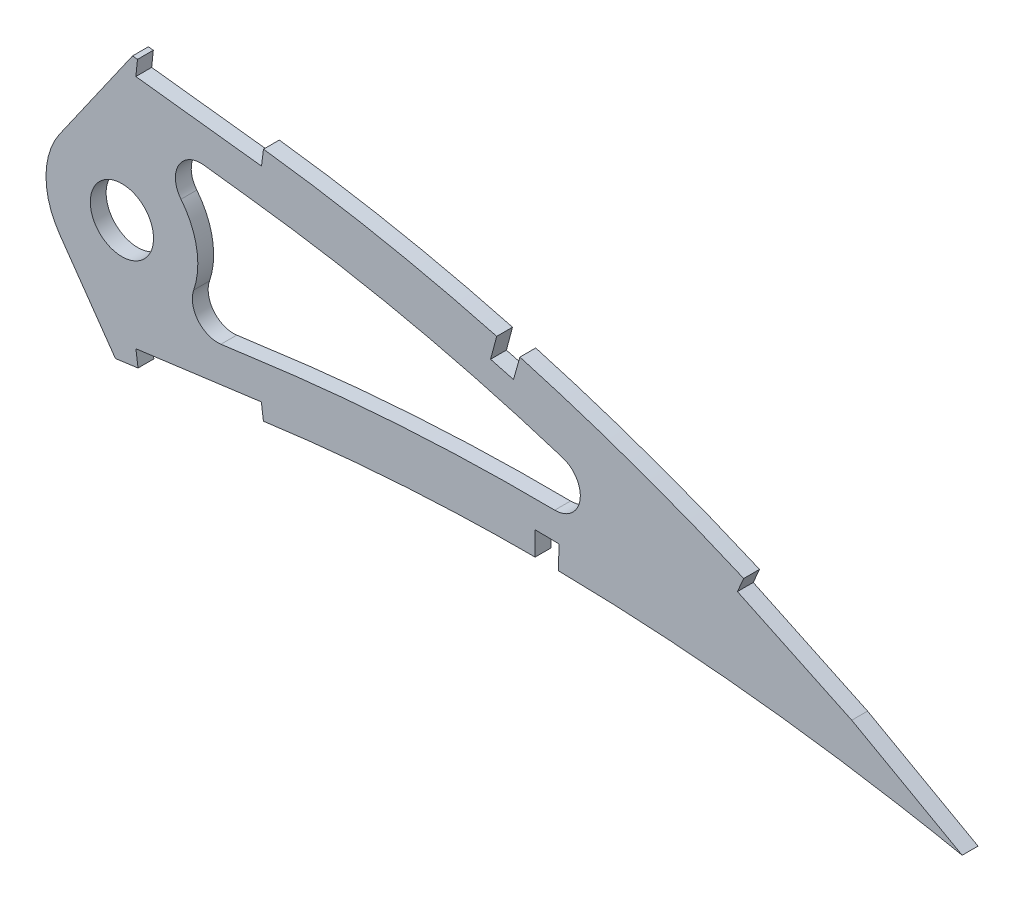
from build123d import *

# Parameters (mm, degrees)
BOSS_EXTRUDE1_DEPTH = 3.175
SKETCH3_R           = 6.35
CUT_EXTRUDE2_DEPTH  = 7.62
CUT_EXTRUDE3_DEPTH  = 4.1750001
FILLET1_R           = 5.08


with BuildPart() as part:
    # Sketch1 → Boss-Extrude1 (new body)
    with BuildSketch(Plane.XY):
        with BuildLine():
            Line((485.587399664, -0.75798934), (490.147728055, -1.684578565))
            Line((490.147728055, -1.684578565), (486.193791136, 0.75798934))
            add(Edge.make_bspline(
                [(486.193791136, 0.75798934), (486.156545565, 0.780998011), (486.007707871, 0.872943377), (485.672349582, 1.078647636), (485.113908292, 1.42125844), (484.332139179, 1.898395939), (483.327649378, 2.508793191), (482.099933618, 3.248176053), (480.649758178, 4.11414228), (478.977474042, 5.102596174), (477.083252712, 6.208909725), (474.9678154, 7.428600903), (472.631346146, 8.754764469), (470.074750091, 10.181981707), (467.298904376, 11.703464898), (464.304334104, 13.312342155), (461.092111509, 15.00042968), (457.663469746, 16.760467008), (454.019033833, 18.582734695), (450.160522056, 20.459648763), (446.08922006, 22.381851369), (441.806517314, 24.339086509), (437.314874314, 26.32337623), (432.615532729, 28.322383702), (427.711170694, 30.327448406), (422.603876177, 32.32715893), (417.296673201, 34.312408193), (411.791609239, 36.270335128), (406.092799427, 38.19238362), (400.203008281, 40.066067188), (394.126447785, 41.881210299), (387.866648542, 43.626044211), (381.42882875, 45.291620487), (374.81707141, 46.865809768), (368.036980395, 48.338075006), (361.093945075, 49.699552264), (353.993788332, 50.936649002), (346.7561854, 52.048400815), (339.497587697, 52.97319004), (332.253923966, 53.880196397), (325.021047815, 54.732245847), (317.699770737, 55.548201081), (310.297136308, 56.323468086), (302.820487344, 57.055622539), (295.277392798, 57.741504683), (287.675691417, 58.379102964), (280.022738792, 58.964804598), (272.326604726, 59.497707184), (264.594897726, 59.973125915), (256.835853078, 60.39070372), (249.05734719, 60.747528421), (241.267474913, 61.041141246), (233.474507978, 61.269769861), (225.686535745, 61.431223873), (217.911990598, 61.524488163), (210.158959277, 61.547014441), (202.435870244, 61.498399603), (194.750810842, 61.376974546), (187.112218127, 61.181076903), (179.528190462, 60.910341158), (172.006928802, 60.56488465), (164.556668167, 60.141814477), (157.185490761, 59.643826715), (149.90160498, 59.068829465), (142.713013757, 58.416669795), (135.627250794, 57.690066178), (128.652204991, 56.887042275), (121.795351463, 56.009883049), (115.064190238, 55.060308222), (108.466273869, 54.03780049), (102.008670179, 52.945313451), (95.69834878, 51.783964779), (89.541985966, 50.557159213), (83.546284377, 49.265216856), (77.717590812, 47.912013041), (72.061962755, 46.499905586), (66.585479912, 45.031479446), (61.293693841, 43.510258272), (56.191955701, 41.93969324), (51.286212878, 40.321510147), (46.580173058, 38.661844322), (42.079617138, 36.961873954), (37.787992638, 35.226836263), (33.71032906, 33.459100147), (29.849672544, 31.664054679), (26.210392495, 29.843743399), (22.795082621, 28.003266258), (19.607171667, 26.145445317), (16.649728276, 24.273731457), (13.923995526, 22.392872215), (11.433731376, 20.504048278), (9.179791317, 18.61203256), (7.163601692, 16.719706143), (5.388044474, 14.828372521), (3.853055719, 12.941362387), (2.560647106, 11.060170164), (1.511042845, 9.186575935), (0.706617001, 7.321940679), (0.14657185, 5.467313049), (-0.159993132, 3.625430402), (-0.236298987, 1.794816138), (-0.078648638, 0.597378122), (0, 0)],
                knots=[0, 0, 0, 0, 0.00025409, 0.001015373, 0.002283359, 0.004056577, 0.006330982, 0.009105274, 0.012374489, 0.016134023, 0.020379661, 0.025105976, 0.030306237, 0.035972206, 0.042099522, 0.048678064, 0.055701664, 0.063160184, 0.071045824, 0.079349827, 0.08806291, 0.097175757, 0.106678111, 0.116561573, 0.126814276, 0.137428301, 0.148393618, 0.15969976, 0.171338125, 0.183297699, 0.195569604, 0.208143556, 0.221011593, 0.234161831, 0.24758745, 0.261276822, 0.27522271, 0.289414144, 0.3037712, 0.317689226, 0.331784111, 0.346039677, 0.36044387, 0.374982721, 0.389640454, 0.404403317, 0.4192566, 0.434186749, 0.449177265, 0.464214782, 0.479284009, 0.49436974, 0.509457833, 0.524532346, 0.53957932, 0.554582984, 0.569529546, 0.584403417, 0.599190992, 0.613876838, 0.628447475, 0.642888675, 0.657186054, 0.671325546, 0.685294014, 0.699078147, 0.712665095, 0.726042645, 0.739197713, 0.752117586, 0.764792042, 0.777208152, 0.789355685, 0.80122396, 0.812803686, 0.824082909, 0.835054602, 0.845709571, 0.856037853, 0.866033834, 0.875688843, 0.884997719, 0.893953426, 0.902552897, 0.910789386, 0.918660734, 0.926166253, 0.933302626, 0.94007122, 0.94647478, 0.952517526, 0.958204819, 0.963546652, 0.9685566, 0.973249913, 0.977651041, 0.981787043, 0.985694226, 0.989415109, 0.993001157, 0.996508416, 1, 1, 1, 1], degree=3))
            add(Edge.make_bspline(
                [(0, 0), (0.124852845, -0.589388692), (0.375132337, -1.770874799), (1.055109044, -3.471725282), (1.954345773, -5.106735278), (3.091715472, -6.671561797), (4.459655687, -8.165777182), (6.055145152, -9.59093561), (7.876619233, -10.946270738), (9.92169391, -12.231165798), (12.187398396, -13.446984767), (14.671186068, -14.592971696), (17.370792198, -15.668768481), (20.283275494, -16.672937055), (23.405075375, -17.607006726), (26.733223776, -18.468701274), (30.263936284, -19.259225009), (33.993816996, -19.976560109), (37.918801514, -20.621435301), (42.034812323, -21.193489669), (46.337624631, -21.693081077), (50.82301706, -22.119161118), (55.4865531, -22.47264634), (60.323584549, -22.753771214), (65.329416188, -22.963427152), (70.499252954, -23.100817142), (75.828031579, -23.168083162), (81.310936338, -23.16623498), (86.942603653, -23.09477832), (92.718222737, -22.957660649), (98.632251256, -22.754013473), (104.679350026, -22.486301136), (110.854064483, -22.157217858), (117.150856575, -21.767879174), (123.564184912, -21.320010643), (130.088480981, -20.817203984), (136.717818035, -20.260713235), (143.446414433, -19.653782206), (150.268313286, -18.999449162), (157.177620607, -18.29978506), (164.168237687, -17.558081099), (171.233938121, -16.77674083), (178.368711149, -15.959932594), (185.566039209, -15.10913432), (192.819836156, -14.229203613), (200.123278023, -13.321821748), (207.470257634, -12.390483576), (214.854167095, -11.43957439), (222.268093801, -10.46898568), (229.705802131, -9.485632582), (237.16011938, -8.488705064), (244.624557097, -7.483330472), (252.092205531, -6.472633763), (259.555791095, -5.456925983), (267.00875308, -4.440416464), (274.444177456, -3.425895825), (281.854781181, -2.413456633), (289.233859631, -1.408131206), (296.573982386, -0.40979664), (303.868380953, 0.579523), (311.110065241, 1.55687475), (318.292203182, 2.521024953), (325.407385919, 3.471363717), (332.448454941, 4.408247897), (339.302915498, 5.303240759), (345.952856872, 6.204000824), (352.420688138, 6.942424504), (358.80798662, 7.572695641), (365.121387221, 8.089431053), (371.353308903, 8.500064921), (377.496611311, 8.807531395), (383.543972889, 9.016123146), (389.487754946, 9.132028332), (395.320533551, 9.158188245), (401.034347101, 9.102945563), (406.621764277, 8.970753247), (412.074986888, 8.767544827), (417.386407281, 8.500176147), (422.548480993, 8.175935919), (427.553458197, 7.799606866), (432.394364707, 7.379974648), (437.06373176, 6.923182232), (441.554389355, 6.434448486), (445.859785012, 5.92401425), (449.973027478, 5.395240442), (453.887929886, 4.85681652), (457.598190253, 4.314198878), (461.097932514, 3.774315295), (464.381658048, 3.242315892), (467.444062607, 2.72526199), (470.280349076, 2.227984348), (472.885595604, 1.755339323), (475.25618804, 1.313290259), (477.38744454, 0.904033197), (479.2765147, 0.534312721), (480.919885909, 0.205760173), (482.315149055, -0.076995438), (483.459867496, -0.312838295), (484.352302675, -0.497896754), (484.990691913, -0.632466588), (485.3743447, -0.712542465), (485.54480657, -0.748903783), (485.587399664, -0.75798934)],
                knots=[0, 0, 0, 0, 0.003638255, 0.007293231, 0.011028136, 0.014901081, 0.018963272, 0.023258475, 0.027820626, 0.032679082, 0.03785316, 0.043361875, 0.049214679, 0.055422346, 0.061988786, 0.068918036, 0.076211157, 0.083868392, 0.091887411, 0.100265912, 0.108999867, 0.118084529, 0.127514843, 0.13728527, 0.147387917, 0.157816481, 0.168563473, 0.179619128, 0.190977373, 0.202626974, 0.214560478, 0.226767249, 0.239236417, 0.251959004, 0.264923894, 0.278119703, 0.291536035, 0.30516028, 0.318980685, 0.332985499, 0.34716279, 0.361498603, 0.375980747, 0.390597192, 0.405332593, 0.420174823, 0.435109533, 0.450124276, 0.465203068, 0.480333154, 0.495500583, 0.510689775, 0.525887334, 0.541078314, 0.556247233, 0.571381785, 0.58646604, 0.601484516, 0.616424329, 0.631269423, 0.646006524, 0.660620684, 0.675098188, 0.689422858, 0.703581824, 0.716907564, 0.730009274, 0.742952128, 0.755725558, 0.768319952, 0.780724337, 0.792926528, 0.804916041, 0.816679084, 0.828203524, 0.8394749, 0.850481359, 0.861207697, 0.871639326, 0.881763414, 0.891563605, 0.901027364, 0.910138977, 0.918883976, 0.927249278, 0.935221104, 0.942784738, 0.949928188, 0.956638464, 0.962904204, 0.968712288, 0.974054485, 0.978918432, 0.983297218, 0.987180246, 0.990560674, 0.993433357, 0.995790626, 0.997629587, 0.998945816, 0.999736592, 1, 1, 1, 1], degree=3))
        make_face()
    extrude(amount=BOSS_EXTRUDE1_DEPTH)

    # Sketch3 → Cut-Extrude2 (cut)
    with BuildSketch(Plane(origin=(0, 0, 0), x_dir=(-1, 0, 0), z_dir=(0, 0, -1))):
        with Locations((-312.347728055, 26.255421435)):
            Circle(SKETCH3_R)
    extrude(amount=-CUT_EXTRUDE2_DEPTH, mode=Mode.SUBTRACT)

    # Sketch4 → Cut-Extrude3 (cut, through all)
    with BuildSketch(Plane.XY.offset(3.175)):
        with BuildLine():
            ThreePointArc((328.764508398, 44.057939686), (323.718114066, 41.472789893), (324.209352335, 35.824092683))
            ThreePointArc((324.209352335, 35.824092683), (326.71833615, 31.329199415), (327.587728055, 26.255421435))
            ThreePointArc((327.587728055, 26.255421435), (325.504689508, 18.564389947), (319.825002945, 12.975814504))
            add(Edge.make_bspline(
                [(319.825002945, 12.975814504), (322.942820543, 13.392982967), (327.669877473, 14.024410231), (334.043339236, 14.862306396), (338.826488009, 15.492744251), (343.715664565, 16.151243809), (350.398623717, 16.952918213), (358.659540226, 17.783012705), (371.975290063, 18.792080277), (388.632726581, 19.430303401), (408.634763224, 19.217007594), (423.010853589, 18.377885686), (430.71684566, 17.722490027), (431.790737707, 17.62717887)],
                knots=[0.666430442, 0.666430442, 0.666430442, 0.666430442, 0.68544632, 0.695276122, 0.705105925, 0.714935727, 0.72476553, 0.744425135, 0.76408474, 0.80340395, 0.84272316, 0.88204237, 0.888412077, 0.888412077, 0.888412077, 0.888412077], degree=3))
            add(Edge.make_bspline(
                [(431.790737707, 17.62717887), (424.191477956, 20.8804212), (410.26123131, 26.282114189), (389.664440925, 32.773092285), (373.49731798, 36.840967689), (360.45479955, 39.506645362), (350.575577074, 41.228299699), (342.418796355, 42.368826827), (335.861477143, 43.188937517), (332.31248965, 43.629530132), (330.029806008, 43.906550774), (329.186314467, 44.00766024), (328.764508398, 44.057939686)],
                knots=[0.110005658, 0.110005658, 0.110005658, 0.110005658, 0.159341904, 0.19917738, 0.239012856, 0.258930594, 0.278848332, 0.298766071, 0.30872494, 0.317222758, 0.319712475, 0.322202192, 0.322202192, 0.322202192, 0.322202192], degree=3))
        make_face()
        with BuildLine():
            add(Edge.make_bspline(
                [(340.771051926, 52.809255955), (340.321486075, 52.866397518), (337.492730725, 53.224225716), (332.253923966, 53.880196397), (325.021047815, 54.732245847), (319.418146413, 55.356688369), (316.22734967, 55.698361537), (315.478729578, 55.7777567)],
                knots=[0.301141045, 0.301141045, 0.301141045, 0.301141045, 0.3037712, 0.317689226, 0.331784111, 0.346039677, 0.350408935, 0.350408935, 0.350408935, 0.350408935], degree=3))
            Line((315.478729578, 55.7777567), (315.143881725, 52.620463253))
            Line((315.143881725, 52.620463253), (340.370717936, 49.659596022))
            Line((340.370717936, 49.659596022), (340.771051926, 52.809255955))
        make_face()
        with BuildLine():
            ThreePointArc((299.8638509, 17.514116545), (297.107728055, 26.255421435), (299.8638509, 34.996726325))
            Line((299.8638509, 34.996726325), (307.815975435, 46.353537128))
            Line((307.815975435, 46.353537128), (314.488133694, 55.882366646))
            add(Edge.make_bspline(
                [(314.488133694, 55.882366646), (313.098819132, 56.028454072), (309.217441166, 56.429197753), (302.820487344, 57.055622539), (295.277392798, 57.741504683), (287.675691417, 58.379102964), (280.022738792, 58.964804598), (272.326604726, 59.497707184), (264.594897726, 59.973125915), (256.835853078, 60.39070372), (249.05734719, 60.747528421), (241.267474913, 61.041141246), (233.474507978, 61.269769861), (225.686535745, 61.431223873), (217.911990598, 61.524488163), (210.158959277, 61.547014441), (202.435870244, 61.498399603), (194.750810842, 61.376974546), (187.112218127, 61.181076903), (179.528190462, 60.910341158), (172.957215359, 60.608531938), (168.9157909, 60.387388325), (167.381438987, 60.29830405)],
                knots=[0.35233602, 0.35233602, 0.35233602, 0.35233602, 0.36044387, 0.374982721, 0.389640454, 0.404403317, 0.4192566, 0.434186749, 0.449177265, 0.464214782, 0.479284009, 0.49436974, 0.509457833, 0.524532346, 0.53957932, 0.554582984, 0.569529546, 0.584403417, 0.599190992, 0.613876838, 0.628447475, 0.637367617, 0.637367617, 0.637367617, 0.637367617], degree=3))
            add(Edge.make_bspline(
                [(167.381438987, 60.29830405), (166.431762902, 60.243165979), (163.023204812, 60.038215562), (157.185490761, 59.643826715), (149.90160498, 59.068829465), (142.713013757, 58.416669795), (135.627250794, 57.690066178), (128.652204991, 56.887042275), (121.795351463, 56.009883049), (115.064190238, 55.060308222), (108.466273869, 54.03780049), (102.008670179, 52.945313451), (95.69834878, 51.783964779), (89.541985966, 50.557159213), (83.546284377, 49.265216856), (77.717590812, 47.912013041), (72.061962755, 46.499905586), (66.585479912, 45.031479446), (61.293693841, 43.510258272), (56.191955701, 41.93969324), (51.286212878, 40.321510147), (46.580173058, 38.661844322), (42.079617138, 36.961873954), (37.787992638, 35.226836263), (33.71032906, 33.459100147), (29.849672544, 31.664054679), (26.210392495, 29.843743399), (22.795082621, 28.003266258), (19.607171667, 26.145445317), (16.649728276, 24.273731457), (13.923995526, 22.392872215), (11.433731376, 20.504048278), (9.179791317, 18.61203256), (7.163601692, 16.719706143), (5.388044474, 14.828372521), (3.853055719, 12.941362387), (2.560647106, 11.060170164), (1.511042845, 9.186575935), (0.706617001, 7.321940679), (0.14657185, 5.467313049), (-0.159993132, 3.625430402), (-0.236298987, 1.794816138), (-0.078648638, 0.597378122), (0, 0)],
                knots=[0.637367617, 0.637367617, 0.637367617, 0.637367617, 0.642888675, 0.657186054, 0.671325546, 0.685294014, 0.699078147, 0.712665095, 0.726042645, 0.739197713, 0.752117586, 0.764792042, 0.777208152, 0.789355685, 0.80122396, 0.812803686, 0.824082909, 0.835054602, 0.845709571, 0.856037853, 0.866033834, 0.875688843, 0.884997719, 0.893953426, 0.902552897, 0.910789386, 0.918660734, 0.926166253, 0.933302626, 0.94007122, 0.94647478, 0.952517526, 0.958204819, 0.963546652, 0.9685566, 0.973249913, 0.977651041, 0.981787043, 0.985694226, 0.989415109, 0.993001157, 0.996508416, 1, 1, 1, 1], degree=3))
            add(Edge.make_bspline(
                [(0, 0), (0.124852845, -0.589388692), (0.375132337, -1.770874799), (1.055109044, -3.471725282), (1.954345773, -5.106735278), (3.091715472, -6.671561797), (4.459655687, -8.165777182), (6.055145152, -9.59093561), (7.876619233, -10.946270738), (9.92169391, -12.231165798), (12.187398396, -13.446984767), (14.671186068, -14.592971696), (17.370792198, -15.668768481), (20.283275494, -16.672937055), (23.405075375, -17.607006726), (26.733223776, -18.468701274), (30.263936284, -19.259225009), (33.993816996, -19.976560109), (37.918801514, -20.621435301), (42.034812323, -21.193489669), (46.337624631, -21.693081077), (50.82301706, -22.119161118), (55.4865531, -22.47264634), (60.323584549, -22.753771214), (65.329416188, -22.963427152), (70.499252954, -23.100817142), (75.828031579, -23.168083162), (81.310936338, -23.16623498), (86.942603653, -23.09477832), (92.718222737, -22.957660649), (98.632251256, -22.754013473), (104.679350026, -22.486301136), (110.854064483, -22.157217858), (117.150856575, -21.767879174), (123.564184912, -21.320010643), (130.088480981, -20.817203984), (136.717818035, -20.260713235), (143.446414433, -19.653782206), (150.268313286, -18.999449162), (157.177620607, -18.29978506), (164.168237687, -17.558081099), (170.39777491, -16.869205546), (174.296068693, -16.425603932), (175.839087806, -16.248124407)],
                knots=[0, 0, 0, 0, 0.003638255, 0.007293231, 0.011028136, 0.014901081, 0.018963272, 0.023258475, 0.027820626, 0.032679082, 0.03785316, 0.043361875, 0.049214679, 0.055422346, 0.061988786, 0.068918036, 0.076211157, 0.083868392, 0.091887411, 0.100265912, 0.108999867, 0.118084529, 0.127514843, 0.13728527, 0.147387917, 0.157816481, 0.168563473, 0.179619128, 0.190977373, 0.202626974, 0.214560478, 0.226767249, 0.239236417, 0.251959004, 0.264923894, 0.278119703, 0.291536035, 0.30516028, 0.318980685, 0.332985499, 0.34716279, 0.361498603, 0.370892639, 0.370892639, 0.370892639, 0.370892639], degree=3))
            add(Edge.make_bspline(
                [(175.839087806, -16.248124407), (176.674835819, -16.151995877), (179.911166249, -15.777598522), (185.566039209, -15.10913432), (192.819836156, -14.229203613), (200.123278023, -13.321821748), (207.470257634, -12.390483576), (214.854167095, -11.43957439), (222.268093801, -10.46898568), (229.705802131, -9.485632582), (237.16011938, -8.488705064), (244.624557097, -7.483330472), (252.092205531, -6.472633763), (259.555791095, -5.456925983), (267.00875308, -4.440416464), (274.444177456, -3.425895825), (281.854781181, -2.413456633), (289.233859631, -1.408131206), (296.573982386, -0.40979664), (303.839629429, 0.575623508), (308.657990094, 1.225937821), (311.044058633, 1.547125156)],
                knots=[0.370892639, 0.370892639, 0.370892639, 0.370892639, 0.375980747, 0.390597192, 0.405332593, 0.420174823, 0.435109533, 0.450124276, 0.465203068, 0.480333154, 0.495500583, 0.510689775, 0.525887334, 0.541078314, 0.556247233, 0.571381785, 0.58646604, 0.601484516, 0.616424329, 0.631269423, 0.645831036, 0.645831036, 0.645831036, 0.645831036], degree=3))
            Line((311.044058633, 1.547125156), (304.484880691, 10.91460206))
            Line((304.484880691, 10.91460206), (299.8638509, 17.514116545))
        make_face()
        with BuildLine():
            Line((315.158704756, 5.303615051), (315.580892501, 2.156809924))
            add(Edge.make_bspline(
                [(315.580892501, 2.156809924), (316.492147075, 2.279067419), (319.775884235, 2.719192684), (325.407385919, 3.471363717), (332.448454941, 4.408247897), (337.557936241, 5.075397303), (340.317929562, 5.444028001), (340.757486099, 5.502711912)],
                knots=[0.655059839, 0.655059839, 0.655059839, 0.655059839, 0.660620684, 0.675098188, 0.689422858, 0.703581824, 0.706263911, 0.706263911, 0.706263911, 0.706263911], degree=3))
            Line((340.757486099, 5.502711912), (340.337329046, 8.649788818))
            Line((340.337329046, 8.649788818), (315.158704756, 5.303615051))
        make_face()
        with BuildLine():
            add(Edge.make_bspline(
                [(395.301483032, 9.144612566), (395.320970567, 9.144563444), (396.890118785, 9.140495622), (398.459241636, 9.12737708), (400.008751567, 9.105526513)],
                knots=[0.81656122, 0.81656122, 0.81656122, 0.81656122, 0.816679084, 0.826051711, 0.826051711, 0.826051711, 0.826051711], degree=3))
            Line((400.008751567, 9.105526513), (400.07551444, 13.839945249))
            Line((400.07551444, 13.839945249), (395.313487893, 13.907097436))
            Line((395.313487893, 13.907097436), (395.301483032, 9.144612566))
        make_face()
        with BuildLine():
            add(Edge.make_bspline(
                [(392.24679827, 42.397573765), (390.803868257, 42.805366815), (389.252466711, 43.233052791), (387.698201472, 43.650087262), (387.592146791, 43.678490243)],
                knots=[0.19944107, 0.19944107, 0.19944107, 0.19944107, 0.208143556, 0.208780766, 0.208780766, 0.208780766, 0.208780766], degree=3))
            Line((387.592146791, 43.678490243), (386.360099239, 39.078113619))
            Line((386.360099239, 39.078113619), (390.960475863, 37.846066067))
            Line((390.960475863, 37.846066067), (392.24679827, 42.397573765))
        make_face()
        with BuildLine():
            Line((435.915330369, 23.456995031), (453.357244423, 15.184029685))
            add(Edge.make_bspline(
                [(453.357244423, 15.184029685), (455.48639778, 14.891160478), (457.613108624, 14.583518449), (459.737403271, 14.261412173)],
                knots=[0.931189609, 0.931189609, 0.931189609, 0.931189609, 0.943905597, 0.943905597, 0.943905597, 0.943905597], degree=3))
            Line((459.737403271, 14.261412173), (460.321736424, 15.392692447))
            add(Edge.make_bspline(
                [(460.321736424, 15.392692447), (459.458167286, 15.838746435), (457.383392025, 16.90050969), (454.019033833, 18.582734695), (450.160522056, 20.459648763), (446.08922006, 22.381851369), (441.806517314, 24.339086509), (438.808273951, 25.663631556), (437.241501932, 26.342621223), (437.17697451, 26.370563129)],
                knots=[0.057519044, 0.057519044, 0.057519044, 0.057519044, 0.063160184, 0.071045824, 0.079349827, 0.08806291, 0.097175757, 0.106678111, 0.107086222, 0.107086222, 0.107086222, 0.107086222], degree=3))
            Line((437.17697451, 26.370563129), (435.915330369, 23.456995031))
        make_face()
        with BuildLine():
            Line((459.737403271, 14.261412173), (458.864665934, 12.571775826))
            Line((458.864665934, 12.571775826), (481.03757378, 0.181369955))
            Line((481.03757378, 0.181369955), (482.674936027, 2.901603377))
            add(Edge.make_bspline(
                [(482.674936027, 2.901603377), (482.507553579, 3.002354181), (481.857264759, 3.393084752), (480.649758178, 4.11414228), (478.977474042, 5.102596174), (477.083252712, 6.208909725), (474.9678154, 7.428600903), (472.631346146, 8.754764469), (470.074750091, 10.181981707), (467.298904376, 11.703464898), (465.132770238, 12.867252566), (463.893038644, 13.524581965), (463.654594141, 13.65068911)],
                knots=[0.007971399, 0.007971399, 0.007971399, 0.007971399, 0.009105274, 0.012374489, 0.016134023, 0.020379661, 0.025105976, 0.030306237, 0.035972206, 0.042099522, 0.048678064, 0.050243587, 0.050243587, 0.050243587, 0.050243587], degree=3))
            add(Edge.make_bspline(
                [(459.737403271, 14.261412173), (461.044045667, 14.063286307), (462.349773916, 13.859688016), (463.654594141, 13.65068911)],
                knots=[0.943905597, 0.943905597, 0.943905597, 0.943905597, 0.951727135, 0.951727135, 0.951727135, 0.951727135], degree=3))
        make_face()
        with BuildLine():
            add(Edge.make_bspline(
                [(453.357244423, 15.184029685), (455.48639778, 14.891160478), (457.613108624, 14.583518449), (459.737403271, 14.261412173)],
                knots=[0.931189609, 0.931189609, 0.931189609, 0.931189609, 0.943905597, 0.943905597, 0.943905597, 0.943905597], degree=3))
            Line((453.357244423, 15.184029685), (458.864665934, 12.571775826))
            Line((458.864665934, 12.571775826), (459.737403271, 14.261412173))
        make_face()
        with BuildLine():
            Line((460.321736424, 15.392692447), (459.737403271, 14.261412173))
            add(Edge.make_bspline(
                [(459.737403271, 14.261412173), (461.044045667, 14.063286307), (462.349773916, 13.859688016), (463.654594141, 13.65068911)],
                knots=[0.943905597, 0.943905597, 0.943905597, 0.943905597, 0.951727135, 0.951727135, 0.951727135, 0.951727135], degree=3))
            add(Edge.make_bspline(
                [(463.654594141, 13.65068911), (462.82327549, 14.090352092), (461.713005589, 14.672352098), (460.599948434, 15.248989331), (460.321736424, 15.392692447)],
                knots=[0.050243587, 0.050243587, 0.050243587, 0.050243587, 0.055701664, 0.057519044, 0.057519044, 0.057519044, 0.057519044], degree=3))
        make_face()
        with BuildLine():
            Line((482.674936027, 2.901603377), (481.03757378, 0.181369955))
            add(Edge.make_bspline(
                [(481.03757378, 0.181369955), (481.491341815, 0.08995181), (482.326979612, -0.079432851), (483.459867496, -0.312838295), (484.352302675, -0.497896754), (484.990691913, -0.632466588), (485.3743447, -0.712542465), (485.54480657, -0.748903783), (485.587399664, -0.75798934)],
                knots=[0.990633731, 0.990633731, 0.990633731, 0.990633731, 0.993433357, 0.995790626, 0.997629587, 0.998945816, 0.999736592, 1, 1, 1, 1], degree=3))
            Line((485.587399664, -0.75798934), (490.147728055, -1.684578565))
            Line((490.147728055, -1.684578565), (486.193791136, 0.75798934))
            add(Edge.make_bspline(
                [(486.193791136, 0.75798934), (486.156545565, 0.780998011), (486.007707871, 0.872943377), (485.672349582, 1.078647636), (485.113908292, 1.42125844), (484.332139179, 1.898395939), (483.494606333, 2.407338635), (482.917094103, 2.755843647), (482.674936027, 2.901603377)],
                knots=[0, 0, 0, 0, 0.00025409, 0.001015373, 0.002283359, 0.004056577, 0.006330982, 0.007971399, 0.007971399, 0.007971399, 0.007971399], degree=3))
        make_face()
    extrude(amount=-CUT_EXTRUDE3_DEPTH, mode=Mode.SUBTRACT)

    # Fillet1
    fillet1_edges = [part.edges().sort_by_distance(p)[0] for p in [
        (319.825002945, 12.975814504, 1.5875),
        (431.790737707, 17.62717887, 1.5875),
    ]]
    fillet(fillet1_edges, radius=FILLET1_R)


solid = part.part
